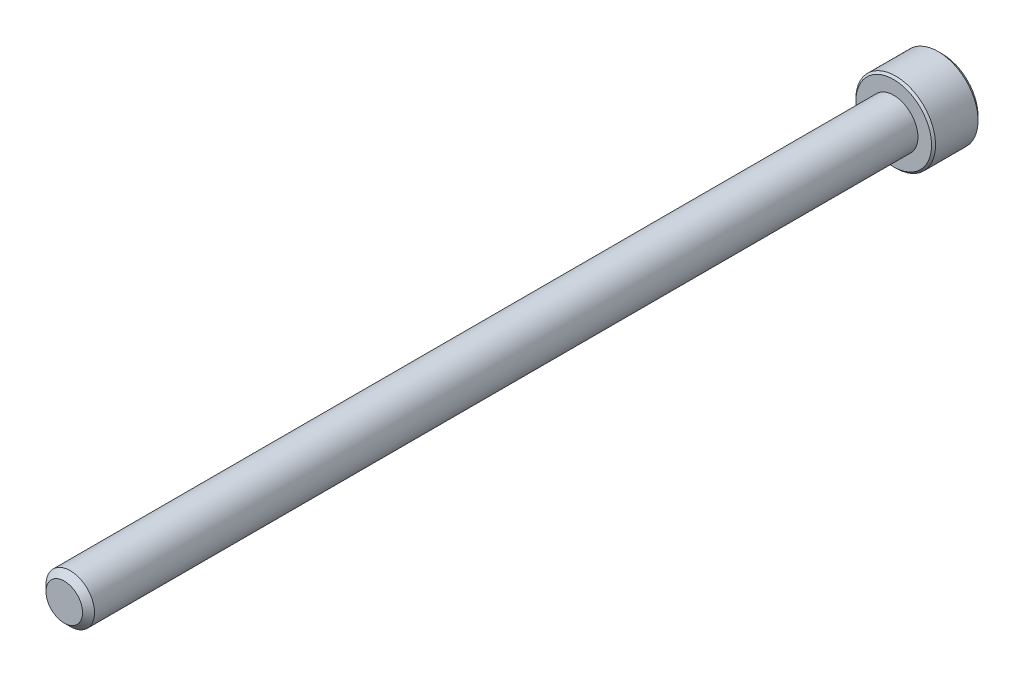
from build123d import *

# Parameters (mm, degrees)
SKETCH1_R          = 2.413
EXTRUDE1_DEPTH     = 82.55
CHAMFER3_SIZE      = 0.5953125
SKETCH6_R          = 3.96875
EXTRUDE2_DEPTH     = 4.826
CUT_EXTRUDE1_DEPTH = 2.9765625
CHAMFER1_SIZE      = 0.396875
CHAMFER2_SIZE      = 0.1984375


with BuildPart() as part:
    # Sketch1 → Extrude1 (new body)
    with BuildSketch(Plane.XY):
        Circle(SKETCH1_R)
    extrude(amount=-EXTRUDE1_DEPTH)

    # Chamfer3
    chamfer3_edges = [part.edges().sort_by_distance(p)[0] for p in [
        (-2.413, 0, 0),
    ]]
    chamfer(chamfer3_edges, length=CHAMFER3_SIZE)

    # Sketch6 → Extrude2 (add)
    with BuildSketch(Plane(origin=(0, 0, -82.55), x_dir=(-1, 0, 0), z_dir=(0, 0, -1))):
        Circle(SKETCH6_R)
    extrude(amount=EXTRUDE2_DEPTH)

    # Sketch7 → Cut-Extrude1 (cut)
    with BuildSketch(Plane(origin=(0, 0, -87.376), x_dir=(-1, 0, 0), z_dir=(0, 0, -1))):
        Polygon((0, 2.291358881), (-1.984375, 1.14567944), (-1.984375, -1.14567944), (0, -2.291358881), (1.984375, -1.14567944), (1.984375, 1.14567944), align=None)
    extrude(amount=-CUT_EXTRUDE1_DEPTH, mode=Mode.SUBTRACT)

    # Cut-Extrude2 cone 1 section (through the dimple's axis) → Cut-Extrude2 (revolve, cut)
    with BuildSketch(Plane(origin=(0, 0, -87.376), x_dir=(0, 1, 0), z_dir=(1, 0, 0))):
        Polygon((0, 0), (2.291358881, 0), (0, 2.291358881), align=None)
    revolve(axis=Axis((0, 0, -87.376), (0, 0, 1)), mode=Mode.SUBTRACT)

    # Chamfer1
    chamfer1_edges = [part.edges().sort_by_distance(p)[0] for p in [
        (3.96875, 0, -87.376),
    ]]
    chamfer(chamfer1_edges, length=CHAMFER1_SIZE)

    # Chamfer2
    chamfer2_edges = [part.edges().sort_by_distance(p)[0] for p in [
        (3.96875, 0, -82.55),
    ]]
    chamfer(chamfer2_edges, length=CHAMFER2_SIZE)


solid = part.part
